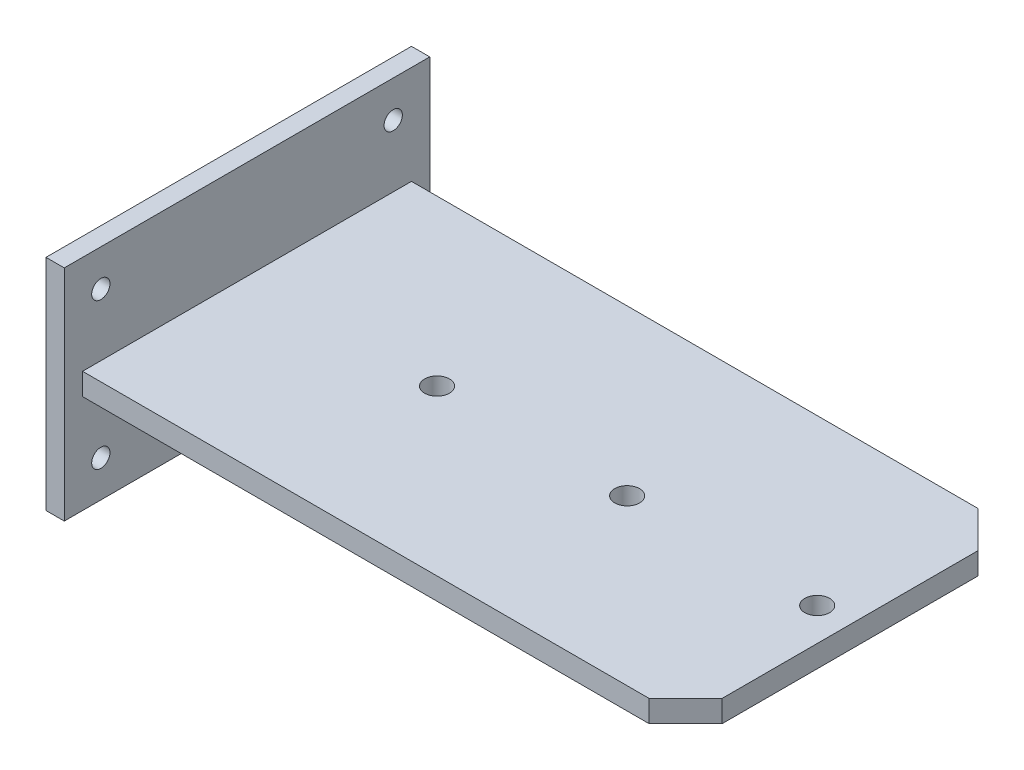
from build123d import *

# Parameters (mm, degrees)
SKETCH_1_W          = 100
SKETCH_1_H          = 60
EXTRUDE_1_DEPTH     = 5
CUT_EXTRUDE_1_REACH = 7
SKETCH_2_R          = 2.5
EXTRUDE_2_DEPTH     = 3
CUT_EXTRUDE_2_REACH = 35
SKETCH_4_R          = 3.4


with BuildPart() as part:
    # 스케치1 → 보스-돌출1 (new body)
    with BuildSketch(Plane(origin=(0, 0, 0), x_dir=(0, 0, -1), z_dir=(1, 0, 0))):
        Rectangle(SKETCH_1_W, SKETCH_1_H)
    extrude(amount=EXTRUDE_1_DEPTH)

    # 스케치2 → 컷-돌출1 (cut, up to next)
    with BuildSketch(Plane(origin=(5, 0, 0), x_dir=(0, 0, -1), z_dir=(1, 0, 0)), mode=Mode.PRIVATE) as cut_extrude_1_sk1:
        with Locations((-40, 20)):
            Circle(SKETCH_2_R)
    cut_extrude_1_tool1 = extrude(cut_extrude_1_sk1.sketch, amount=-CUT_EXTRUDE_1_REACH, mode=Mode.PRIVATE) & part.part
    add(cut_extrude_1_tool1.solids().sort_by_distance((5, 20, 40))[0], mode=Mode.SUBTRACT)
    # 스케치2 → 컷-돌출1 (cut, up to next)
    with BuildSketch(Plane(origin=(5, 0, 0), x_dir=(0, 0, -1), z_dir=(1, 0, 0)), mode=Mode.PRIVATE) as cut_extrude_1_sk2:
        with Locations((-40, -20)):
            Circle(SKETCH_2_R)
    cut_extrude_1_tool2 = extrude(cut_extrude_1_sk2.sketch, amount=-CUT_EXTRUDE_1_REACH, mode=Mode.PRIVATE) & part.part
    add(cut_extrude_1_tool2.solids().sort_by_distance((5, -20, 40))[0], mode=Mode.SUBTRACT)
    # 스케치2 → 컷-돌출1 (cut, up to next)
    with BuildSketch(Plane(origin=(5, 0, 0), x_dir=(0, 0, -1), z_dir=(1, 0, 0)), mode=Mode.PRIVATE) as cut_extrude_1_sk3:
        with Locations((40, -20)):
            Circle(SKETCH_2_R)
    cut_extrude_1_tool3 = extrude(cut_extrude_1_sk3.sketch, amount=-CUT_EXTRUDE_1_REACH, mode=Mode.PRIVATE) & part.part
    add(cut_extrude_1_tool3.solids().sort_by_distance((5, -20, -40))[0], mode=Mode.SUBTRACT)
    # 스케치2 → 컷-돌출1 (cut, up to next)
    with BuildSketch(Plane(origin=(5, 0, 0), x_dir=(0, 0, -1), z_dir=(1, 0, 0)), mode=Mode.PRIVATE) as cut_extrude_1_sk4:
        with Locations((40, 20)):
            Circle(SKETCH_2_R)
    cut_extrude_1_tool4 = extrude(cut_extrude_1_sk4.sketch, amount=-CUT_EXTRUDE_1_REACH, mode=Mode.PRIVATE) & part.part
    add(cut_extrude_1_tool4.solids().sort_by_distance((5, 20, -40))[0], mode=Mode.SUBTRACT)

    # 스케치3 → 보스-돌출2 (add, symmetric)
    with BuildSketch(Plane(origin=(0, 0, 0), x_dir=(1, 0, 0), z_dir=(0, 1, 0))):
        Polygon((170, 35), (160, 45), (5, 45), (5, -45), (160, -45), (170, -35), align=None)
    extrude(amount=EXTRUDE_2_DEPTH, both=True)

    # 스케치4 → 컷-돌출2 (cut, up to next)
    with BuildSketch(Plane(origin=(0, 3, 0), x_dir=(1, 0, 0), z_dir=(0, 1, 0)), mode=Mode.PRIVATE) as cut_extrude_2_sk1:
        with Locations(Location((57, 0, 0), (0, 0, 270))):  # turned: the seam where the file's is
            Circle(SKETCH_4_R)
    cut_extrude_2_tool1 = extrude(cut_extrude_2_sk1.sketch, amount=-CUT_EXTRUDE_2_REACH, mode=Mode.PRIVATE) & part.part
    add(cut_extrude_2_tool1.solids().sort_by_distance((57, 3, 0))[0], mode=Mode.SUBTRACT)
    # 스케치4 → 컷-돌출2 (cut, up to next)
    with BuildSketch(Plane(origin=(0, 3, 0), x_dir=(1, 0, 0), z_dir=(0, 1, 0)), mode=Mode.PRIVATE) as cut_extrude_2_sk2:
        with Locations(Location((109, 0, 0), (0, 0, 270))):  # turned: the seam where the file's is
            Circle(SKETCH_4_R)
    cut_extrude_2_tool2 = extrude(cut_extrude_2_sk2.sketch, amount=-CUT_EXTRUDE_2_REACH, mode=Mode.PRIVATE) & part.part
    add(cut_extrude_2_tool2.solids().sort_by_distance((109, 3, 0))[0], mode=Mode.SUBTRACT)
    # 스케치4 → 컷-돌출2 (cut, up to next)
    with BuildSketch(Plane(origin=(0, 3, 0), x_dir=(1, 0, 0), z_dir=(0, 1, 0)), mode=Mode.PRIVATE) as cut_extrude_2_sk3:
        with Locations(Location((161, 0, 0), (0, 0, 270))):  # turned: the seam where the file's is
            Circle(SKETCH_4_R)
    cut_extrude_2_tool3 = extrude(cut_extrude_2_sk3.sketch, amount=-CUT_EXTRUDE_2_REACH, mode=Mode.PRIVATE) & part.part
    add(cut_extrude_2_tool3.solids().sort_by_distance((161, 3, 0))[0], mode=Mode.SUBTRACT)


solid = part.part
